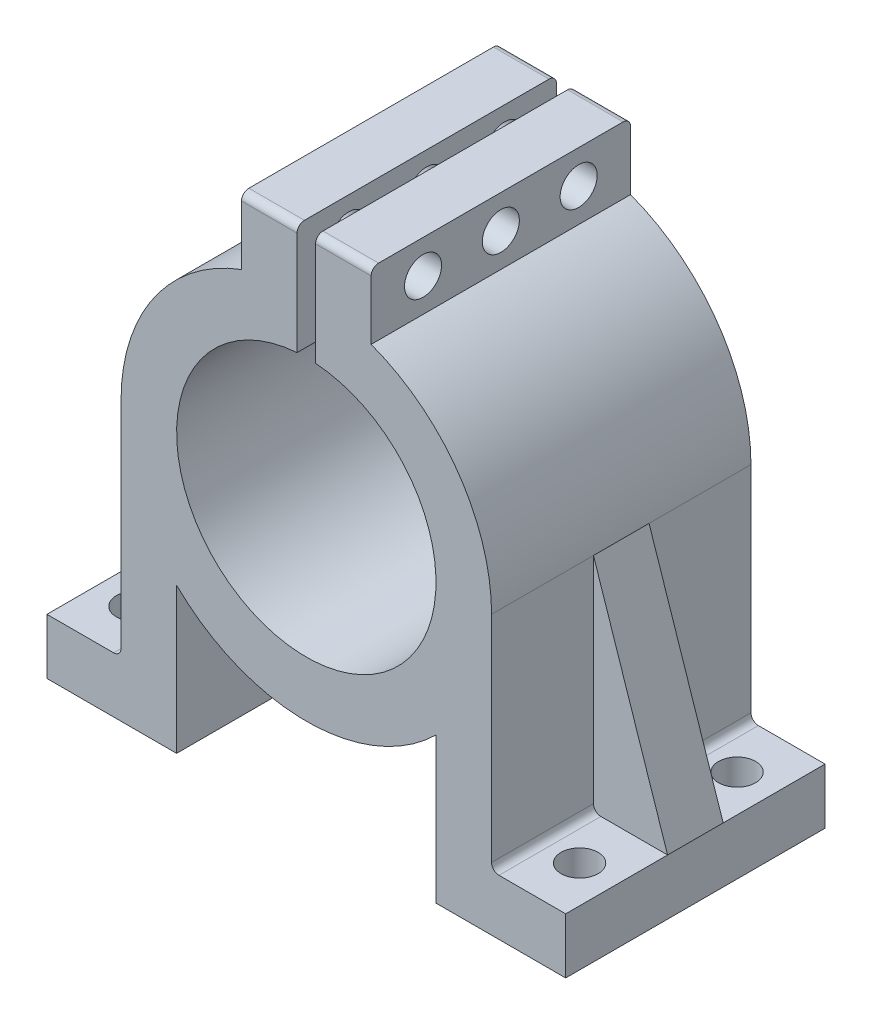
from build123d import *

# Parameters (mm, degrees)
SALIENTE_EXTRUIR1_DEPTH    = 14
CROQUIS2_W                 = 0.4
CROQUIS2_H                 = 0.4
CORTAR_EXTRUIR1_DEPTH      = 1
CORTAR_EXTRUIR1_DEPTH_BACK = 15
SALIENTE_EXTRUIR2_DEPTH    = 14
CORTAR_EXTRUIR2_DEPTH      = 1
CORTAR_EXTRUIR2_DEPTH_BACK = 5.5
CORTAR_EXTRUIR3_DEPTH      = 5.5
SALIENTE_EXTRUIR3_DEPTH    = 14
CROQUIS7_R                 = 1
CORTAR_EXTRUIR4_DEPTH      = 4
REDONDEO3_R                = 0.4
CROQUIS9_R                 = 1
CORTAR_EXTRUIR5_DEPTH      = 18.5


with BuildPart() as part:
    # Croquis1 → Saliente-Extruir1 (new body)
    with BuildSketch(Plane.XY):
        with BuildLine():
            Line((0.5, 6.982120022), (0.5, 12.967496998))
            Line((0.5, 12.967496998), (3.5, 12.967496998))
            Line((3.5, 12.967496998), (3.5, 9.367496998))
            ThreePointArc((3.5, 9.367496998), (8.215838363, 5.700877125), (10, 0))
            Line((10, 0), (10, -11.6))
            ThreePointArc((10, -11.6), (10.117157288, -11.882842712), (10.4, -12))
            Line((10.4, -12), (14, -12))
            Line((14, -12), (14, -15))
            Line((14, -15), (7, -15))
            Line((7, -15), (7, -7.141428429))
            ThreePointArc((7, -7.141428429), (0, -10), (-7, -7.141428429))
            Line((-7, -7.141428429), (-7, -15))
            Line((-7, -15), (-14, -15))
            Line((-14, -15), (-14, -12))
            Line((-14, -12), (-10.4, -12))
            ThreePointArc((-10.4, -12), (-10.117157288, -11.882842712), (-10, -11.6))
            Line((-10, -11.6), (-10, 0))
            ThreePointArc((-10, 0), (-8.215838363, 5.700877125), (-3.5, 9.367496998))
            Line((-3.5, 9.367496998), (-3.5, 12.967496998))
            Line((-3.5, 12.967496998), (-0.5, 12.967496998))
            Line((-0.5, 12.967496998), (-0.5, 6.982120022))
            ThreePointArc((-0.5, 6.982120022), (0, -7), (0.5, 6.982120022))
        make_face()
    extrude(amount=SALIENTE_EXTRUIR1_DEPTH)

    # Croquis2 → Cortar-Extruir1 (cut, two sides)
    with BuildSketch(Plane.XY.offset(14)) as cortar_extruir1_sk:
        with Locations((-7.2, -14.8)):
            Rectangle(CROQUIS2_W, CROQUIS2_H)
        with Locations((7.2, -14.8)):
            Rectangle(CROQUIS2_W, CROQUIS2_H)
    extrude(amount=CORTAR_EXTRUIR1_DEPTH, mode=Mode.SUBTRACT)
    extrude(cortar_extruir1_sk.sketch, amount=-CORTAR_EXTRUIR1_DEPTH_BACK, mode=Mode.SUBTRACT)

    # Croquis4 → Saliente-Extruir2 (add, through all)
    with BuildSketch(Plane.XY.offset(14)):
        Polygon((-14, -12), (-10, 0), (-10, -12), align=None)
        Polygon((14, -12), (10, 0), (10, -12), align=None)
    extrude(amount=-SALIENTE_EXTRUIR2_DEPTH)

    # Croquis5 → Cortar-Extruir2 (cut, two sides)
    with BuildSketch(Plane.XY.offset(14)) as cortar_extruir2_sk:
        Polygon((-14, -12), (-10, 0), (-10, -12), align=None)
        Polygon((14, -12), (10, 0), (10, -12), align=None)
    extrude(amount=CORTAR_EXTRUIR2_DEPTH, mode=Mode.SUBTRACT)
    extrude(cortar_extruir2_sk.sketch, amount=-CORTAR_EXTRUIR2_DEPTH_BACK, mode=Mode.SUBTRACT)

    # Croquis6 → Cortar-Extruir3 (cut)
    with BuildSketch(Plane(origin=(0, 0, 0), x_dir=(-1, 0, 0), z_dir=(0, 0, -1))):
        Polygon((-14, -12), (-10, 0), (-10, -12), align=None)
        Polygon((14, -12), (10, 0), (10, -12), align=None)
    extrude(amount=-CORTAR_EXTRUIR3_DEPTH, mode=Mode.SUBTRACT)

    # Croquis1_2 → Saliente-Extruir3 (add, through all)
    with BuildSketch(Plane.XY):
        with BuildLine():
            Line((0.5, 6.982120022), (0.5, 12.967496998))
            Line((0.5, 12.967496998), (3.5, 12.967496998))
            Line((3.5, 12.967496998), (3.5, 9.367496998))
            ThreePointArc((3.5, 9.367496998), (8.215838363, 5.700877125), (10, 0))
            Line((10, 0), (10, -11.6))
            ThreePointArc((10, -11.6), (10.117157288, -11.882842712), (10.4, -12))
            Line((10.4, -12), (14, -12))
            Line((14, -12), (14, -15))
            Line((14, -15), (7, -15))
            Line((7, -15), (7, -7.141428429))
            ThreePointArc((7, -7.141428429), (0, -10), (-7, -7.141428429))
            Line((-7, -7.141428429), (-7, -15))
            Line((-7, -15), (-14, -15))
            Line((-14, -15), (-14, -12))
            Line((-14, -12), (-10.4, -12))
            ThreePointArc((-10.4, -12), (-10.117157288, -11.882842712), (-10, -11.6))
            Line((-10, -11.6), (-10, 0))
            ThreePointArc((-10, 0), (-8.215838363, 5.700877125), (-3.5, 9.367496998))
            Line((-3.5, 9.367496998), (-3.5, 12.967496998))
            Line((-3.5, 12.967496998), (-0.5, 12.967496998))
            Line((-0.5, 12.967496998), (-0.5, 6.982120022))
            ThreePointArc((-0.5, 6.982120022), (0, -7), (0.5, 6.982120022))
        make_face()
    extrude(amount=SALIENTE_EXTRUIR3_DEPTH)

    # Croquis7 → Cortar-Extruir4 (cut, through all)
    with BuildSketch(Plane(origin=(0, -12, 0), x_dir=(1, 0, 0), z_dir=(0, 1, 0))):
        with Locations((-12, -11.25)):
            Circle(CROQUIS7_R)
        with Locations((-12, -2.75)):
            Circle(CROQUIS7_R)
        with Locations((12, -2.75)):
            Circle(CROQUIS7_R)
        with Locations((12, -11.25)):
            Circle(CROQUIS7_R)
    extrude(amount=-CORTAR_EXTRUIR4_DEPTH, mode=Mode.SUBTRACT)

    # Redondeo3
    redondeo3_edges = [part.edges().sort_by_distance(p)[0] for p in [
        (-2, 12.967496998, 0),
        (2, 12.967496998, 14),
        (-2, 12.967496998, 14),
        (2, 12.967496998, 0),
    ]]
    fillet(redondeo3_edges, radius=REDONDEO3_R)

    # Croquis9 → Cortar-Extruir5 (cut, through all)
    with BuildSketch(Plane.ZY.offset(3.5)):
        with Locations((2.8, 11.167496998)):
            Circle(CROQUIS9_R)
        with Locations((7.000061, 11.167496998)):
            Circle(CROQUIS9_R)
        with Locations((11.200061, 11.167496998)):
            Circle(CROQUIS9_R)
    extrude(amount=-CORTAR_EXTRUIR5_DEPTH, mode=Mode.SUBTRACT)


solid = part.part
